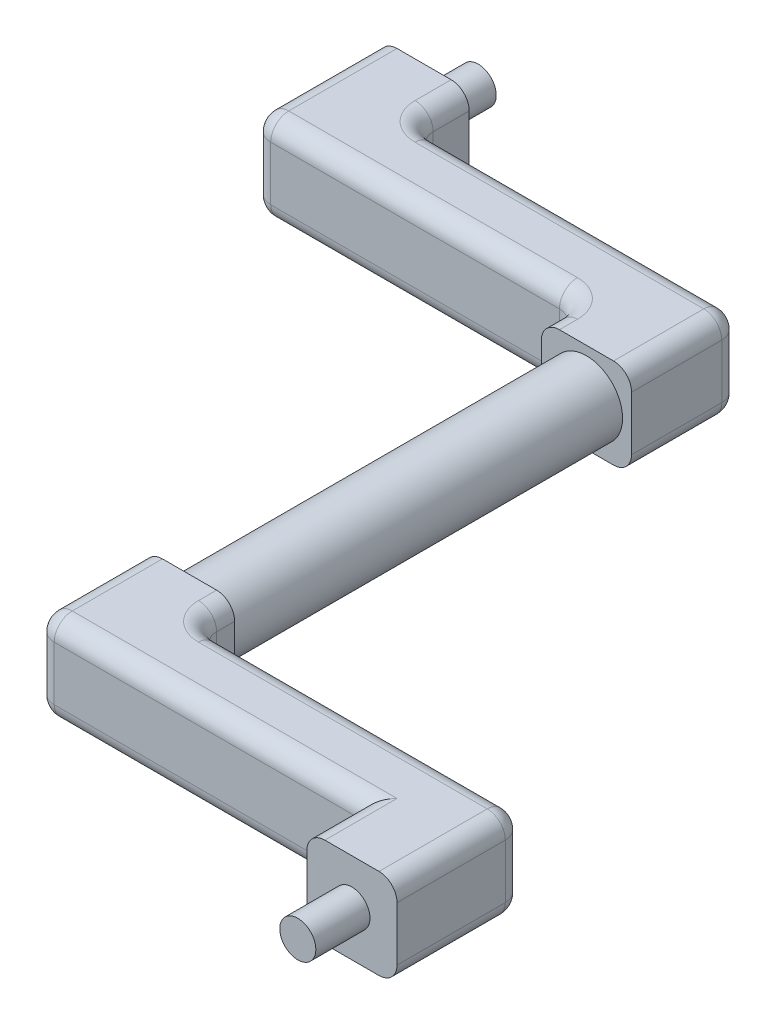
from build123d import *

# Parameters (mm, degrees)
CROQUIS3_R                   = 12.7
SALIENTE_EXTRUIR1_DEPTH      = 50.8
SALIENTE_EXTRUIR1_DEPTH_BACK = 88.9
CROQUIS4_W                   = 31.75
CROQUIS4_H                   = 31.75
SALIENTE_EXTRUIR2_DEPTH      = 38.1
CROQUIS6_W                   = 25.4
CROQUIS6_H                   = 31.75
SALIENTE_EXTRUIR3_DEPTH      = 114.3
CROQUIS8_W                   = 31.75
CROQUIS8_H                   = 31.75
SALIENTE_EXTRUIR4_DEPTH      = 19.05
CROQUIS9_R                   = 6.35
SALIENTE_EXTRUIR5_DEPTH      = 19.05
REDONDEO1_R                  = 6.35
CROQUIS12_W                  = 31.75
CROQUIS12_H                  = 31.75
SALIENTE_EXTRUIR6_DEPTH      = 38.1
CROQUIS13_W                  = 25.4
CROQUIS13_H                  = 31.75
SALIENTE_EXTRUIR7_DEPTH      = 114.3
CROQUIS14_W                  = 31.75
CROQUIS14_H                  = 31.75
SALIENTE_EXTRUIR8_DEPTH      = 19.05
CROQUIS16_R                  = 6.35
SALIENTE_EXTRUIR9_DEPTH      = 19.05
REDONDEO2_R                  = 6.35


with BuildPart() as part:
    # Croquis3 → Saliente-Extruir1 (new body, two sides)
    with BuildSketch(Plane.XY) as saliente_extruir1_sk:
        Circle(CROQUIS3_R)
    extrude(amount=SALIENTE_EXTRUIR1_DEPTH)
    extrude(saliente_extruir1_sk.sketch, amount=-SALIENTE_EXTRUIR1_DEPTH_BACK)

    # Croquis4 → Saliente-Extruir2 (add)
    with BuildSketch(Plane(origin=(0, 0, -88.9), x_dir=(-1, 0, 0), z_dir=(0, 0, -1))):
        Rectangle(CROQUIS4_W, CROQUIS4_H)
    extrude(amount=SALIENTE_EXTRUIR2_DEPTH)

    # Croquis6 → Saliente-Extruir3 (add)
    with BuildSketch(Plane.ZY.offset(15.875)):
        with Locations((-114.3, 0)):
            Rectangle(CROQUIS6_W, CROQUIS6_H)
    extrude(amount=SALIENTE_EXTRUIR3_DEPTH)

    # Croquis8 → Saliente-Extruir4 (add)
    with BuildSketch(Plane(origin=(0, 0, -127), x_dir=(-1, 0, 0), z_dir=(0, 0, -1))):
        with Locations((114.3, 0)):
            Rectangle(CROQUIS8_W, CROQUIS8_H)
    extrude(amount=SALIENTE_EXTRUIR4_DEPTH)

    # Croquis9 → Saliente-Extruir5 (add)
    with BuildSketch(Plane(origin=(0, 0, -146.05), x_dir=(-1, 0, 0), z_dir=(0, 0, -1))):
        with Locations((114.3, 0)):
            Circle(CROQUIS9_R)
    extrude(amount=SALIENTE_EXTRUIR5_DEPTH)

    # Redondeo1
    redondeo1_edges = [part.edges().sort_by_distance(p)[0] for p in [
        (15.875, 0, -127),
        (-41.275, -15.875, -127),
        (-15.875, 15.875, -95.25),
        (-15.875, -15.875, -95.25),
        (-15.875, 0, -101.6),
        (-73.025, -15.875, -101.6),
        (-73.025, 15.875, -101.6),
        (-130.175, -15.875, -123.825),
        (-130.175, 0, -101.6),
        (-130.175, 15.875, -123.825),
        (-41.275, 15.875, -127),
        (-98.425, 0, -127),
        (-98.425, 15.875, -136.525),
        (-98.425, -15.875, -136.525),
        (15.875, 15.875, -107.95),
        (15.875, -15.875, -107.95),
    ]]
    fillet(redondeo1_edges, radius=REDONDEO1_R)

    # Croquis12 → Saliente-Extruir6 (add)
    with BuildSketch(Plane.XY.offset(50.8)):
        Rectangle(CROQUIS12_W, CROQUIS12_H)
    extrude(amount=SALIENTE_EXTRUIR6_DEPTH)

    # Croquis13 → Saliente-Extruir7 (add)
    with BuildSketch(Plane(origin=(15.875, 0, 0), x_dir=(0, 0, -1), z_dir=(1, 0, 0))):
        with Locations((-76.2, 0)):
            Rectangle(CROQUIS13_W, CROQUIS13_H)
    extrude(amount=SALIENTE_EXTRUIR7_DEPTH)

    # Croquis14 → Saliente-Extruir8 (add)
    with BuildSketch(Plane.XY.offset(88.9)):
        with Locations((114.3, 0)):
            Rectangle(CROQUIS14_W, CROQUIS14_H)
    extrude(amount=SALIENTE_EXTRUIR8_DEPTH)

    # Croquis16 → Saliente-Extruir9 (add)
    with BuildSketch(Plane.XY.offset(107.95)):
        with Locations((114.3, 0)):
            Circle(CROQUIS16_R)
    extrude(amount=SALIENTE_EXTRUIR9_DEPTH)

    # Redondeo2
    redondeo2_edges = [part.edges().sort_by_distance(p)[0] for p in [
        (-15.875, 15.875, 69.85),
        (-15.875, -15.875, 69.85),
        (-15.875, 0, 88.9),
        (41.275, -15.875, 88.9),
        (15.875, 15.875, 57.15),
        (15.875, -15.875, 57.15),
        (15.875, 0, 63.5),
        (73.025, -15.875, 63.5),
        (73.025, 15.875, 63.5),
        (130.175, -15.875, 85.725),
        (130.175, 0, 63.5),
        (130.175, 15.875, 85.725),
        (41.275, 15.875, 88.9),
        (98.425, 15.875, 98.425),
        (98.425, -15.875, 98.425),
    ]]
    fillet(redondeo2_edges, radius=REDONDEO2_R)


solid = part.part
